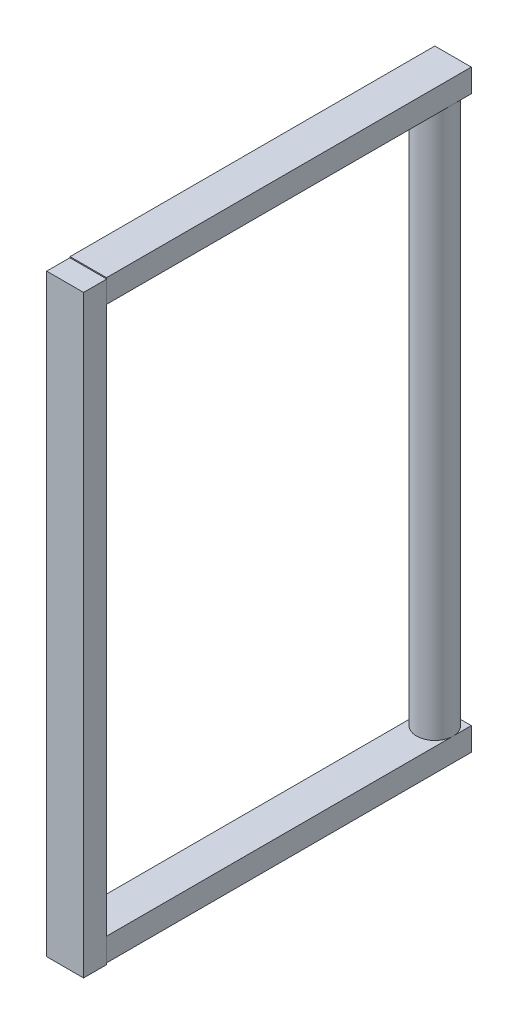
from build123d import *

# Parameters (mm, degrees)
SKETCH1_R           = 2
BOSS_EXTRUDE1_DEPTH = 60
SKETCH2_W           = 4
SKETCH2_H           = 40
BOSS_EXTRUDE2_DEPTH = 2.54
SKETCH3_W           = 4
SKETCH3_H           = 40
BOSS_EXTRUDE3_DEPTH = 2.54
SKETCH4_W           = 4.044012612
SKETCH4_H           = 65.108603045
BOSS_EXTRUDE4_DEPTH = 2.54


with BuildPart() as part:
    # Sketch1 → Boss-Extrude1 (new body)
    with BuildSketch(Plane(origin=(0, 0, 0), x_dir=(1, 0, 0), z_dir=(0, 1, 0))):
        Circle(SKETCH1_R)
    extrude(amount=BOSS_EXTRUDE1_DEPTH)

    # Sketch2 → Boss-Extrude2 (add)
    with BuildSketch(Plane.XZ):
        with Locations((0, 18)):
            Rectangle(SKETCH2_W, SKETCH2_H)
    extrude(amount=BOSS_EXTRUDE2_DEPTH)

    # Sketch3 → Boss-Extrude3 (add)
    with BuildSketch(Plane(origin=(0, 60, 0), x_dir=(1, 0, 0), z_dir=(0, 1, 0))):
        with Locations((0, -18)):
            Rectangle(SKETCH3_W, SKETCH3_H)
    extrude(amount=BOSS_EXTRUDE3_DEPTH)

    # Sketch4 → Boss-Extrude4 (add)
    with BuildSketch(Plane.XY.offset(38)):
        with Locations((0, 29.86519958)):
            Rectangle(SKETCH4_W, SKETCH4_H)
    extrude(amount=BOSS_EXTRUDE4_DEPTH)


solid = part.part
